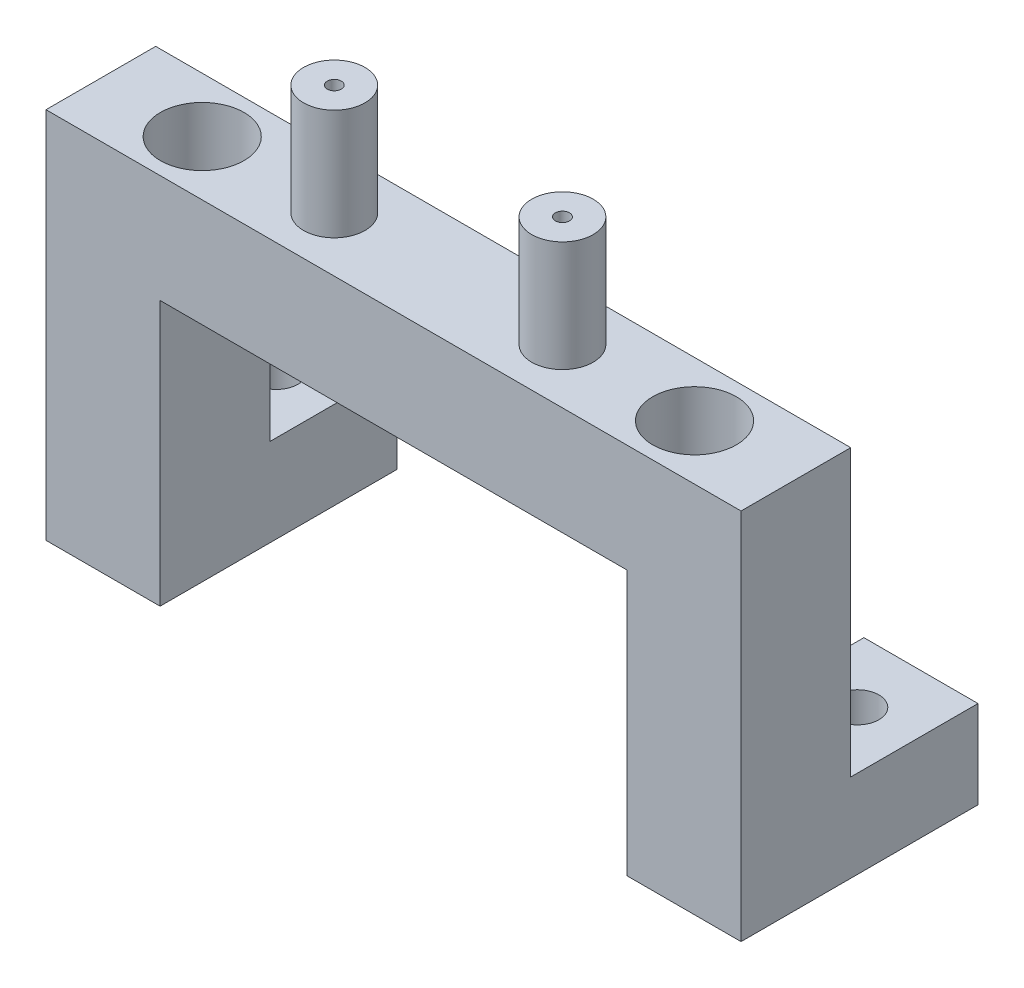
from build123d import *

# Parameters (mm, degrees)
BOSS_EXTRUDE1_DEPTH              = 12.5
SKETCH8_W                        = 13
SKETCH8_H                        = 10
BOSS_EXTRUDE2_DEPTH              = 14.5
F_10_0_1935_DIAMETER_HOLE1_D     = 4.9149
SKETCH14_R                       = 3.5
BOSS_EXTRUDE3_DEPTH              = 12.6
SKETCH23_R                       = 0.8
CUT_EXTRUDE3_DEPTH               = 30
SKETCH24_R                       = 0.8
CUT_EXTRUDE4_DEPTH               = 30
F_3_8_0_375_DIAMETER_HOLE5_D     = 9.525
F_3_8_0_375_DIAMETER_HOLE5_DEPTH = 10
F_3_8_0_375_DIAMETER_HOLE5_TIP   = 2.861598698


with BuildPart() as part:
    # Sketch6 → Boss-Extrude1 (new body)
    with BuildSketch(Plane.XY):
        Polygon((-54.693316182, -23.370226934), (-54.693316182, 19.129773066), (-15.093316182, 19.129773066), (-15.093316182, 6.803860506), (-41.693316182, 6.803860506), (-41.693316182, -23.370226934), align=None)
    extrude(amount=BOSS_EXTRUDE1_DEPTH)

    # Sketch8 → Boss-Extrude2 (add)
    with BuildSketch(Plane(origin=(0, 0, 0), x_dir=(-1, 0, 0), z_dir=(0, 0, -1))):
        with Locations((48.193316182, -18.370226934)):
            Rectangle(SKETCH8_W, SKETCH8_H)
    extrude(amount=BOSS_EXTRUDE2_DEPTH)

    # Mirror1: part across plane


with BuildPart() as part_1:
    add(part.part)
    add(part.part.mirror(Plane(origin=(-15.093316182, 6.803860506, 12.5), x_dir=(0, 0, 1), z_dir=(-1, 0, 0))))

    # #10 (0.1935) Diameter Hole1 (through all)
    with Locations(Plane(origin=(0, -13.370226934, 0), x_dir=(1, 0, 0), z_dir=(0, 1, 0))):
        with Locations((-48.193316182, 7.25), (18.006683818, 7.25)):
            Hole(F_10_0_1935_DIAMETER_HOLE1_D / 2)

    # Sketch14 → Boss-Extrude3 (add)
    with BuildSketch(Plane(origin=(0, 19.129773066, 0), x_dir=(1, 0, 0), z_dir=(0, 1, 0))):
        with Locations((-28.093316182, -6.25)):
            Circle(SKETCH14_R)
        with Locations((-2.093316182, -6.25)):
            Circle(SKETCH14_R)
    extrude(amount=BOSS_EXTRUDE3_DEPTH)

    # Sketch23 → Cut-Extrude3 (cut)
    with BuildSketch(Plane(origin=(0, 31.729773066, 0), x_dir=(1, 0, 0), z_dir=(0, 1, 0))):
        with Locations((-2.093316182, -6.25)):
            Circle(SKETCH23_R)
    extrude(amount=-CUT_EXTRUDE3_DEPTH, mode=Mode.SUBTRACT)

    # Sketch24 → Cut-Extrude4 (cut)
    with BuildSketch(Plane(origin=(0, 31.729773066, 0), x_dir=(1, 0, 0), z_dir=(0, 1, 0))):
        with Locations((-28.093316182, -6.25)):
            Circle(SKETCH24_R)
    extrude(amount=-CUT_EXTRUDE4_DEPTH, mode=Mode.SUBTRACT)

    # 3/8 (0.375) Diameter Hole5
    with Locations(Plane(origin=(-43.143316182, 19.129773066, 6.25), x_dir=(0, 0, 1), z_dir=(0, 1, 0))):
        with Locations((0, 0), (0, 56.1)):
            Hole(F_3_8_0_375_DIAMETER_HOLE5_D / 2, depth=F_3_8_0_375_DIAMETER_HOLE5_DEPTH)
            with Locations((0, 0, -(F_3_8_0_375_DIAMETER_HOLE5_DEPTH + F_3_8_0_375_DIAMETER_HOLE5_TIP / 2))):  # 118° drill point
                Cone(0, F_3_8_0_375_DIAMETER_HOLE5_D / 2, F_3_8_0_375_DIAMETER_HOLE5_TIP, mode=Mode.SUBTRACT)


solid = part_1.part
